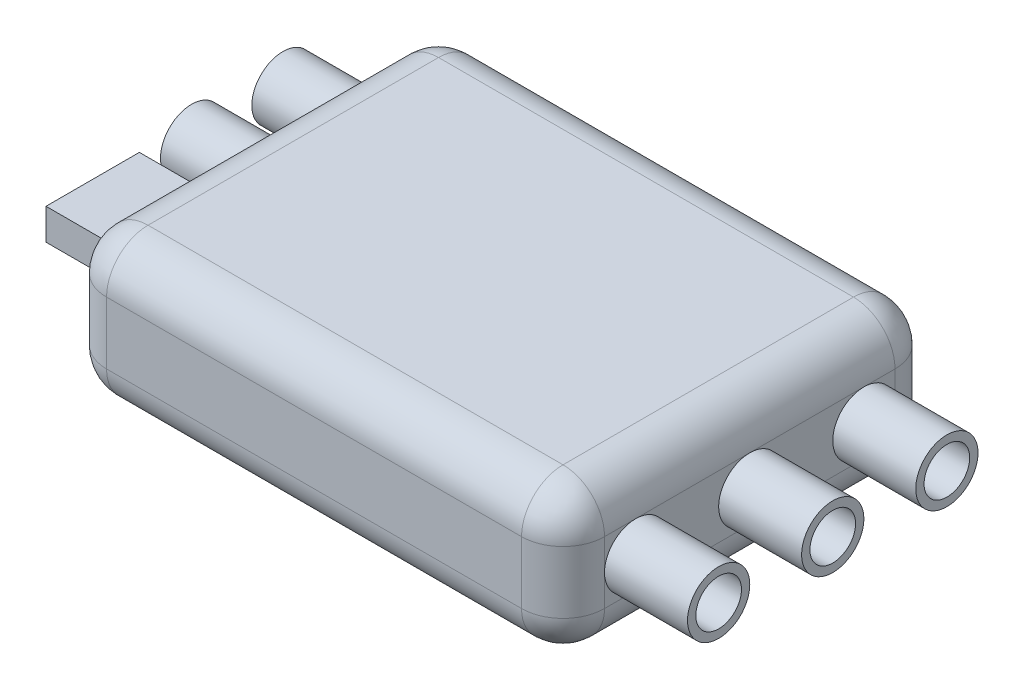
from build123d import *

# Parameters (mm, degrees)
BOSS_EXTRUDE1_DEPTH = 7
FILLET1_R           = 2
SKETCH2_R           = 1.5
SKETCH2_R_2         = 1.1
BOSS_EXTRUDE2_DEPTH = 4
SKETCH3_R           = 1.5
SKETCH3_R_2         = 1.1
SKETCH3_W           = 4.5
SKETCH3_H           = 1.5
BOSS_EXTRUDE3_DEPTH = 4


with BuildPart() as part:
    # Sketch1 → Boss-Extrude1 (new body)
    with BuildSketch(Plane(origin=(0, 0, 0), x_dir=(1, 0, 0), z_dir=(0, 1, 0))):
        with BuildLine():
            Line((-10, -9), (10, -9))
            ThreePointArc((10, -9), (11.414213562, -8.414213562), (12, -7))
            Line((12, -7), (12, 7))
            ThreePointArc((12, 7), (11.414213562, 8.414213562), (10, 9))
            Line((10, 9), (-10, 9))
            ThreePointArc((-10, 9), (-11.414213562, 8.414213562), (-12, 7))
            Line((-12, 7), (-12, -7))
            ThreePointArc((-12, -7), (-11.414213562, -8.414213562), (-10, -9))
        make_face()
    extrude(amount=BOSS_EXTRUDE1_DEPTH)

    # Fillet1
    fillet1_edges = [part.edges().sort_by_distance(p)[0] for p in [
        (11.414213562, 7, 8.414213562),
        (0, 0, 9),
        (-11.414213562, 0, 8.414213562),
        (12, 7, 0),
        (11.414213562, 7, -8.414213562),
        (0, 7, -9),
        (-11.414213562, 7, -8.414213562),
        (-12, 7, 0),
        (-11.414213562, 7, 8.414213562),
        (0, 7, 9),
        (-12, 0, 0),
        (-11.414213562, 0, -8.414213562),
        (0, 0, -9),
        (11.414213562, 0, -8.414213562),
        (12, 0, 0),
        (11.414213562, 0, 8.414213562),
    ]]
    fillet(fillet1_edges, radius=FILLET1_R)

    # Sketch2 → Boss-Extrude2 (add)
    with BuildSketch(Plane(origin=(12, 0, 0), x_dir=(0, 0, -1), z_dir=(1, 0, 0))):
        with Locations((5.5, 3.5)):
            Circle(SKETCH2_R)
        with Locations((5.5, 3.5)):
            Circle(SKETCH2_R_2, mode=Mode.SUBTRACT)
        with Locations((0, 3.5)):
            Circle(SKETCH2_R)
        with Locations((0, 3.5)):
            Circle(SKETCH2_R_2, mode=Mode.SUBTRACT)
        with Locations((-5.5, 3.5)):
            Circle(SKETCH2_R)
        with Locations((-5.5, 3.5)):
            Circle(SKETCH2_R_2, mode=Mode.SUBTRACT)
    extrude(amount=BOSS_EXTRUDE2_DEPTH)

    # Sketch3 → Boss-Extrude3 (add)
    with BuildSketch(Plane.ZY.offset(12)):
        with Locations((-5.5, 3.5)):
            Circle(SKETCH3_R)
        with Locations((-5.5, 3.5)):
            Circle(SKETCH3_R_2, mode=Mode.SUBTRACT)
        with Locations((-1.1, 3.5)):
            Circle(SKETCH3_R)
        with Locations((-1.1, 3.5)):
            Circle(SKETCH3_R_2, mode=Mode.SUBTRACT)
        with Locations((3.668705041, 3.5)):
            Rectangle(SKETCH3_W, SKETCH3_H)
    extrude(amount=BOSS_EXTRUDE3_DEPTH)


solid = part.part
